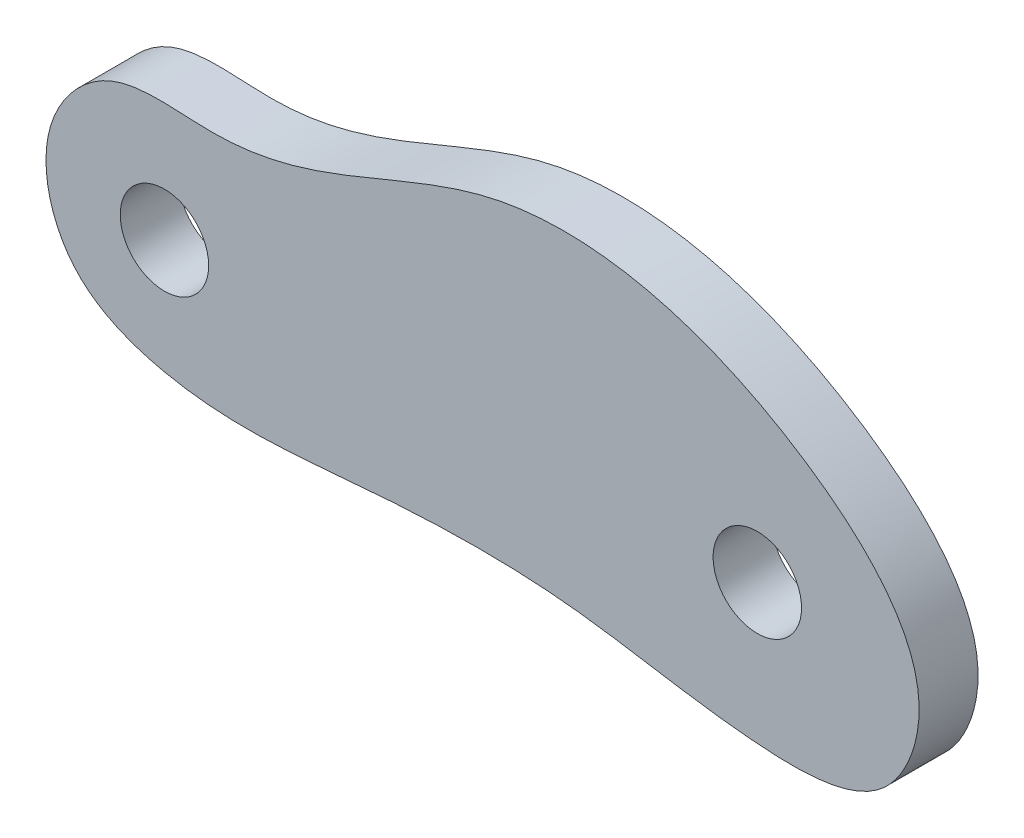
from build123d import *

# Parameters (mm, degrees)
SKETCH1_R           = 2.38125
BOSS_EXTRUDE1_DEPTH = 3.175


with BuildPart() as part:
    # Sketch1 → Boss-Extrude1 (new body)
    with BuildSketch(Plane.XY):
        with BuildLine():
            add(Edge.make_bspline(
                [(256.656307694, 220.658361193), (254.869539647, 221.040175674), (251.013480449, 222.495951077), (249.433947251, 228.891650402), (253.68922329, 233.825733293), (258.820760462, 232.851791162), (265.796638063, 233.919150188), (275.584344016, 239.766153097), (289.391955014, 236.438949771), (298.833553425, 227.380636014), (295.537354238, 219.161240786), (287.15018396, 219.054034587), (278.52707262, 221.094526863), (267.648367821, 220.846256465), (260.423337659, 219.853384524), (256.656307694, 220.658361193)],
                knots=[0, 0, 0, 0, 0.048868391, 0.104913983, 0.150291774, 0.201900731, 0.236561521, 0.344194309, 0.499123451, 0.600926947, 0.643563728, 0.707242057, 0.800186434, 0.89697113, 1, 1, 1, 1], degree=3))
        make_face()
        with Locations((288.590792317, 226.806176415)):
            Circle(SKETCH1_R, mode=Mode.SUBTRACT)
        with Locations((256.656307694, 226.806176415)):
            Circle(SKETCH1_R, mode=Mode.SUBTRACT)
    extrude(amount=BOSS_EXTRUDE1_DEPTH)


solid = part.part
